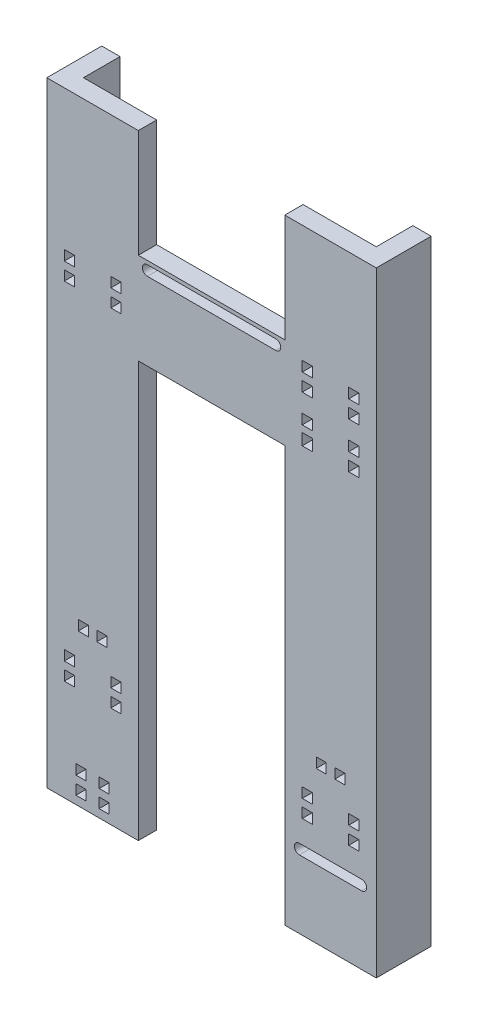
from build123d import *

# Parameters (mm, degrees)
SKETCH2_W           = 25
SKETCH2_H           = 168
BOSS_EXTRUDE1_DEPTH = 5
SKETCH3_W           = 10
SKETCH3_H           = 168
BOSS_EXTRUDE2_DEPTH = 5
SKETCH4_W           = 40
SKETCH4_H           = 25
BOSS_EXTRUDE3_DEPTH = 5
SKETCH5_W           = 25
SKETCH5_H           = 168
BOSS_EXTRUDE4_DEPTH = 5
SKETCH6_W           = 10
SKETCH6_H           = 168
BOSS_EXTRUDE5_DEPTH = 5
CUT_EXTRUDE1_DEPTH  = 5
CUT_EXTRUDE2_DEPTH  = 20
SKETCH9_W           = 2.75
SKETCH9_H           = 2.75
SKETCH9_H_2         = 2.689417066
CUT_EXTRUDE3_DEPTH  = 20
SKETCH10_W          = 2.75
SKETCH10_H          = 2.75
SKETCH10_H_2        = 3.15
CUT_EXTRUDE4_DEPTH  = 20
SKETCH11_W          = 2.75
SKETCH11_H          = 2.75
SKETCH11_W_2        = 2.782071424
SKETCH11_W_3        = 2.74
SKETCH11_H_2        = 2.74
CUT_EXTRUDE5_DEPTH  = 20
SKETCH12_W          = 2.75
SKETCH12_H          = 2.75
CUT_EXTRUDE6_DEPTH  = 20
SKETCH13_W          = 2.75
SKETCH13_H          = 2.75
SKETCH13_W_2        = 2.699527024
CUT_EXTRUDE7_DEPTH  = 20


with BuildPart() as part:
    # Sketch2 → Boss-Extrude1 (new body)
    with BuildSketch(Plane.XY):
        Rectangle(SKETCH2_W, SKETCH2_H)
    extrude(amount=BOSS_EXTRUDE1_DEPTH)

    # Sketch3 → Boss-Extrude2 (add)
    with BuildSketch(Plane.ZY.offset(12.5)):
        with Locations((-5, 0)):
            Rectangle(SKETCH3_W, SKETCH3_H)
    extrude(amount=-BOSS_EXTRUDE2_DEPTH)

    # Sketch4 → Boss-Extrude3 (add)
    with BuildSketch(Plane.XY.offset(5)):
        with Locations((32.5, 42)):
            Rectangle(SKETCH4_W, SKETCH4_H)
    extrude(amount=-BOSS_EXTRUDE3_DEPTH)

    # Sketch5 → Boss-Extrude4 (add)
    with BuildSketch(Plane.XY.offset(5)):
        with Locations((65, 0)):
            Rectangle(SKETCH5_W, SKETCH5_H)
    extrude(amount=-BOSS_EXTRUDE4_DEPTH)

    # Sketch6 → Boss-Extrude5 (add)
    with BuildSketch(Plane(origin=(77.5, 0, 0), x_dir=(0, 0, -1), z_dir=(1, 0, 0))):
        with Locations((5, 0)):
            Rectangle(SKETCH6_W, SKETCH6_H)
    extrude(amount=-BOSS_EXTRUDE5_DEPTH)

    # Sketch7 → Cut-Extrude1 (cut)
    with BuildSketch(Plane.XY.offset(5)):
        with BuildLine():
            Line((14.965887672, 53.5), (50.034112328, 53.5))
            ThreePointArc((50.034112328, 53.5), (51.409112328, 52.125), (50.034112328, 50.75))
            Line((50.034112328, 50.75), (14.965887672, 50.75))
            ThreePointArc((14.965887672, 50.75), (13.590887672, 52.125), (14.965887672, 53.5))
        make_face()
    extrude(amount=-CUT_EXTRUDE1_DEPTH, mode=Mode.SUBTRACT)

    # Sketch8 → Cut-Extrude2 (cut)
    with BuildSketch(Plane.XY.offset(5)):
        with BuildLine():
            Line((73.500571176, -65.375), (56.499428824, -65.375))
            ThreePointArc((56.499428824, -65.375), (55.124428824, -64), (56.499428824, -62.625))
            Line((56.499428824, -62.625), (73.500571176, -62.625))
            ThreePointArc((73.500571176, -62.625), (74.875571176, -64), (73.500571176, -65.375))
        make_face()
    extrude(amount=-CUT_EXTRUDE2_DEPTH, mode=Mode.SUBTRACT)

    # Sketch9 → Cut-Extrude3 (cut)
    with BuildSketch(Plane.XY.offset(5)):
        with Locations((6.35, 44.38125)):
            Rectangle(SKETCH9_W, SKETCH9_H)
        with Locations((-6.35, 44.38125)):
            Rectangle(SKETCH9_W, SKETCH9_H)
        with Locations((-6.35, 39.61875)):
            Rectangle(SKETCH9_W, SKETCH9_H_2)
        with Locations((6.35, 39.61875)):
            Rectangle(SKETCH9_W, SKETCH9_H_2)
    extrude(amount=-CUT_EXTRUDE3_DEPTH, mode=Mode.SUBTRACT)

    # Sketch10 → Cut-Extrude4 (cut)
    with BuildSketch(Plane.XY.offset(5)):
        with Locations((58.65, 50.63125)):
            Rectangle(SKETCH10_W, SKETCH10_H)
        with Locations((71.35, 50.63125)):
            Rectangle(SKETCH10_W, SKETCH10_H)
        with Locations((58.65, 45.86875)):
            Rectangle(SKETCH10_W, SKETCH10_H)
        with Locations((71.35, 45.86875)):
            Rectangle(SKETCH10_W, SKETCH10_H)
        with Locations((71.35, 38.13125)):
            Rectangle(SKETCH10_W, SKETCH10_H)
        with Locations((58.65, 38.13125)):
            Rectangle(SKETCH10_W, SKETCH10_H)
        with Locations((58.65, 33.36875)):
            Rectangle(SKETCH10_W, SKETCH10_H_2)
        with Locations((71.35, 33.36875)):
            Rectangle(SKETCH10_W, SKETCH10_H)
    extrude(amount=-CUT_EXTRUDE4_DEPTH, mode=Mode.SUBTRACT)

    # Sketch11 → Cut-Extrude5 (cut)
    with BuildSketch(Plane.XY.offset(5)):
        with Locations((58.65, -50.24375)):
            Rectangle(SKETCH11_W, SKETCH11_H)
        with Locations((71.35, -50.24375)):
            Rectangle(SKETCH11_W_2, SKETCH11_H)
        with Locations((71.35, -55.00625)):
            Rectangle(SKETCH11_W_3, SKETCH11_H_2)
        with Locations((58.65, -55.00625)):
            Rectangle(SKETCH11_W, SKETCH11_H_2)
        with Locations((-6.35, -50.24375)):
            Rectangle(SKETCH11_W, SKETCH11_H)
        with Locations((6.35, -50.24375)):
            Rectangle(SKETCH11_W, SKETCH11_H)
        with Locations((6.35, -55.00625)):
            Rectangle(SKETCH11_W, SKETCH11_H_2)
        with Locations((-6.35, -55.00625)):
            Rectangle(SKETCH11_W, SKETCH11_H_2)
    extrude(amount=-CUT_EXTRUDE5_DEPTH, mode=Mode.SUBTRACT)

    # Sketch12 → Cut-Extrude6 (cut)
    with BuildSketch(Plane.XY.offset(5)):
        with Locations((-3.175, -75.643809518)):
            Rectangle(SKETCH12_W, SKETCH12_H)
        with Locations((3.175, -75.643809518)):
            Rectangle(SKETCH12_W, SKETCH12_H)
        with Locations((3.175, -80.406309518)):
            Rectangle(SKETCH12_W, SKETCH12_H)
        with Locations((-3.175, -80.406309518)):
            Rectangle(SKETCH12_W, SKETCH12_H)
    extrude(amount=-CUT_EXTRUDE6_DEPTH, mode=Mode.SUBTRACT)

    # Sketch13 → Cut-Extrude7 (cut)
    with BuildSketch(Plane.XY.offset(5)):
        with Locations((-2.54, -41.237096808)):
            Rectangle(SKETCH13_W, SKETCH13_H)
        with Locations((2.54, -41.237096808)):
            Rectangle(SKETCH13_W, SKETCH13_H)
        with Locations((62.46, -41.237096808)):
            Rectangle(SKETCH13_W_2, SKETCH13_H)
        with Locations((67.54, -41.237096808)):
            Rectangle(SKETCH13_W, SKETCH13_H)
    extrude(amount=-CUT_EXTRUDE7_DEPTH, mode=Mode.SUBTRACT)


solid = part.part
